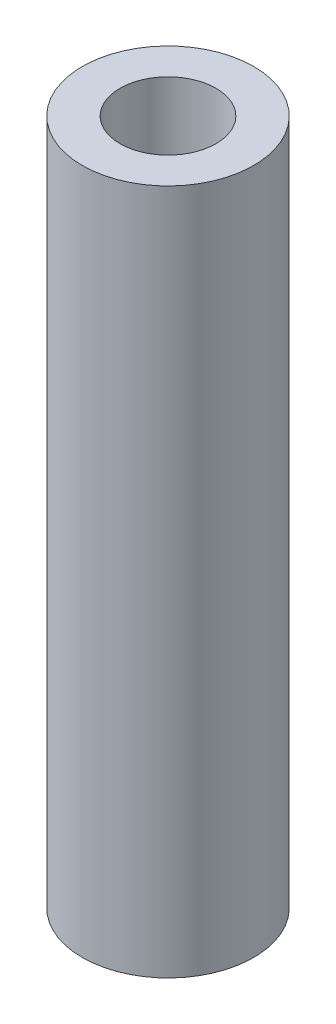
from build123d import *

# Parameters (mm, degrees)
SKETCH1_R           = 2.5
SKETCH1_R_2         = 1.4
BOSS_EXTRUDE1_DEPTH = 20


with BuildPart() as part:
    # Sketch1 → Boss-Extrude1 (new body)
    with BuildSketch(Plane(origin=(0, 0, 0), x_dir=(1, 0, 0), z_dir=(0, 1, 0))):
        Circle(SKETCH1_R)
        Circle(SKETCH1_R_2, mode=Mode.SUBTRACT)
    extrude(amount=BOSS_EXTRUDE1_DEPTH)


solid = part.part
